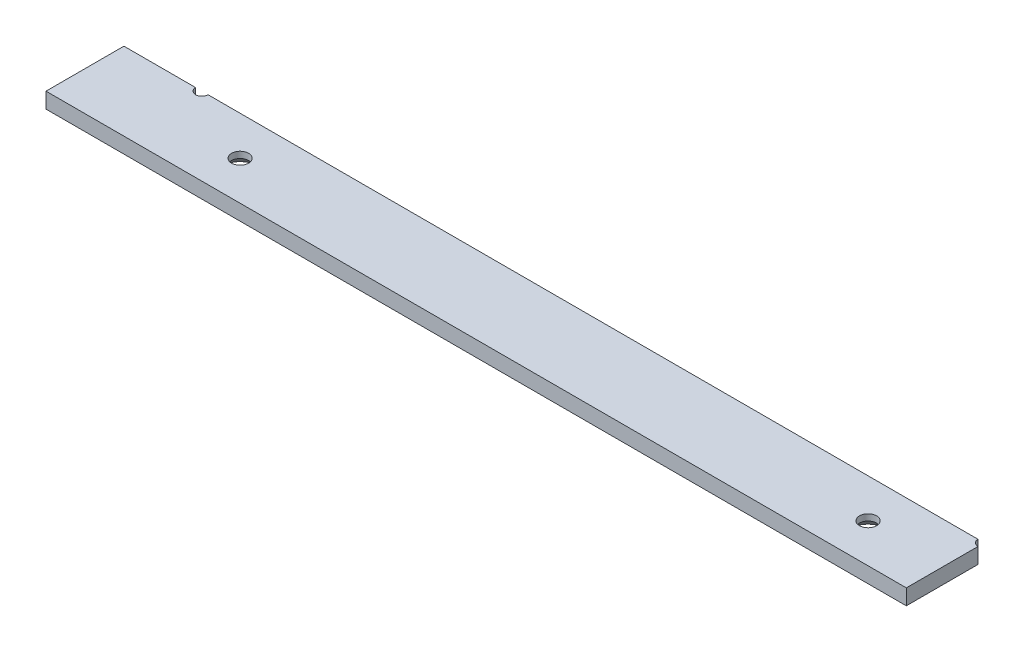
from build123d import *

# Parameters (mm, degrees)
CROQUIS1_W                                           = 276
CROQUIS1_H                                           = 25
SALIENTE_EXTRUIR1_DEPTH                              = 5
CROQUIS2_R                                           = 2
CORTAR_EXTRUIR1_DEPTH                                = 5
AVELLANADO_PARA_TORNILLO_CON_CABEZA_AVEL_D           = 5.5
AVELLANADO_PARA_TORNILLO_CON_CABEZA_AVEL_DEPTH       = 5
AVELLANADO_PARA_TORNILLO_CON_CABEZA_AVEL_CSINK_D     = 11.47
AVELLANADO_PARA_TORNILLO_CON_CABEZA_AVEL_CSINK_ANGLE = 90
AVELLANADO_PARA_TORNILLO_CON_CABEZA_AVEL_TIP         = 1.652366702


with BuildPart() as part:
    # Croquis1 → Saliente-Extruir1 (new body)
    with BuildSketch(Plane(origin=(0, 0, 0), x_dir=(1, 0, 0), z_dir=(0, 1, 0))):
        with Locations((138, 12.5)):
            Rectangle(CROQUIS1_W, CROQUIS1_H)
    extrude(amount=SALIENTE_EXTRUIR1_DEPTH)

    # Croquis2 → Cortar-Extruir1 (cut)
    with BuildSketch(Plane(origin=(0, 5, 0), x_dir=(1, 0, 0), z_dir=(0, 1, 0))):
        with Locations((276, 25)):
            Circle(CROQUIS2_R)
        with Locations((25, 25)):
            Circle(CROQUIS2_R)
    extrude(amount=-CORTAR_EXTRUIR1_DEPTH, mode=Mode.SUBTRACT)

    # Avellanado para tornillo con cabeza avellanada de clavija hexagonal de M51
    with Locations(Plane(origin=(0, 0, 0), x_dir=(-1, 0, 0), z_dir=(0, -1, 0))):
        with Locations((-251.231218281, 12.5), (-49.768781719, 12.5)):
            CounterSinkHole(AVELLANADO_PARA_TORNILLO_CON_CABEZA_AVEL_D / 2, AVELLANADO_PARA_TORNILLO_CON_CABEZA_AVEL_CSINK_D / 2, depth=AVELLANADO_PARA_TORNILLO_CON_CABEZA_AVEL_DEPTH, counter_sink_angle=AVELLANADO_PARA_TORNILLO_CON_CABEZA_AVEL_CSINK_ANGLE)
            with Locations((0, 0, -(AVELLANADO_PARA_TORNILLO_CON_CABEZA_AVEL_DEPTH + AVELLANADO_PARA_TORNILLO_CON_CABEZA_AVEL_TIP / 2))):  # 118° drill point
                Cone(0, AVELLANADO_PARA_TORNILLO_CON_CABEZA_AVEL_D / 2, AVELLANADO_PARA_TORNILLO_CON_CABEZA_AVEL_TIP, mode=Mode.SUBTRACT)


solid = part.part
